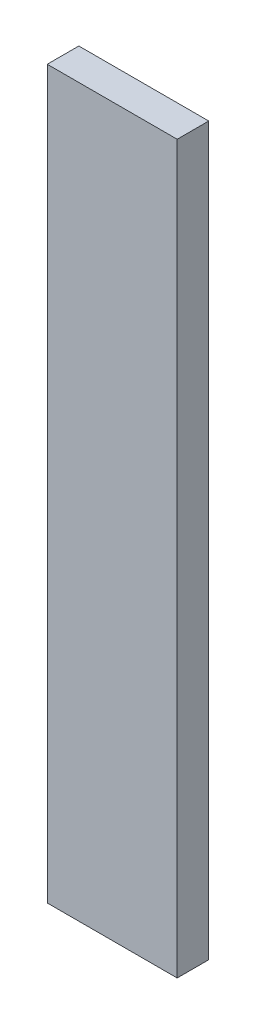
from build123d import *

# Parameters (mm, degrees)
ESQUISSE1_W             = 90.5
ESQUISSE1_H             = 506
BOSS_EXTRU_1_DEPTH      = 22
ESQUISSE2_W             = 12
ESQUISSE2_H             = 486
ENL_V_MAT_EXTRU_1_DEPTH = 7


with BuildPart() as part:
    # Esquisse1 → Boss.-Extru.1 (new body)
    with BuildSketch(Plane.XY):
        with Locations((45.25, -253)):
            Rectangle(ESQUISSE1_W, ESQUISSE1_H)
    extrude(amount=BOSS_EXTRU_1_DEPTH)

    # Esquisse2 → Enlèv. mat.-Extru.1 (cut)
    with BuildSketch(Plane.ZY):
        with Locations((6, -253)):
            Rectangle(ESQUISSE2_W, ESQUISSE2_H)
    extrude(amount=-ENL_V_MAT_EXTRU_1_DEPTH, mode=Mode.SUBTRACT)


solid = part.part
